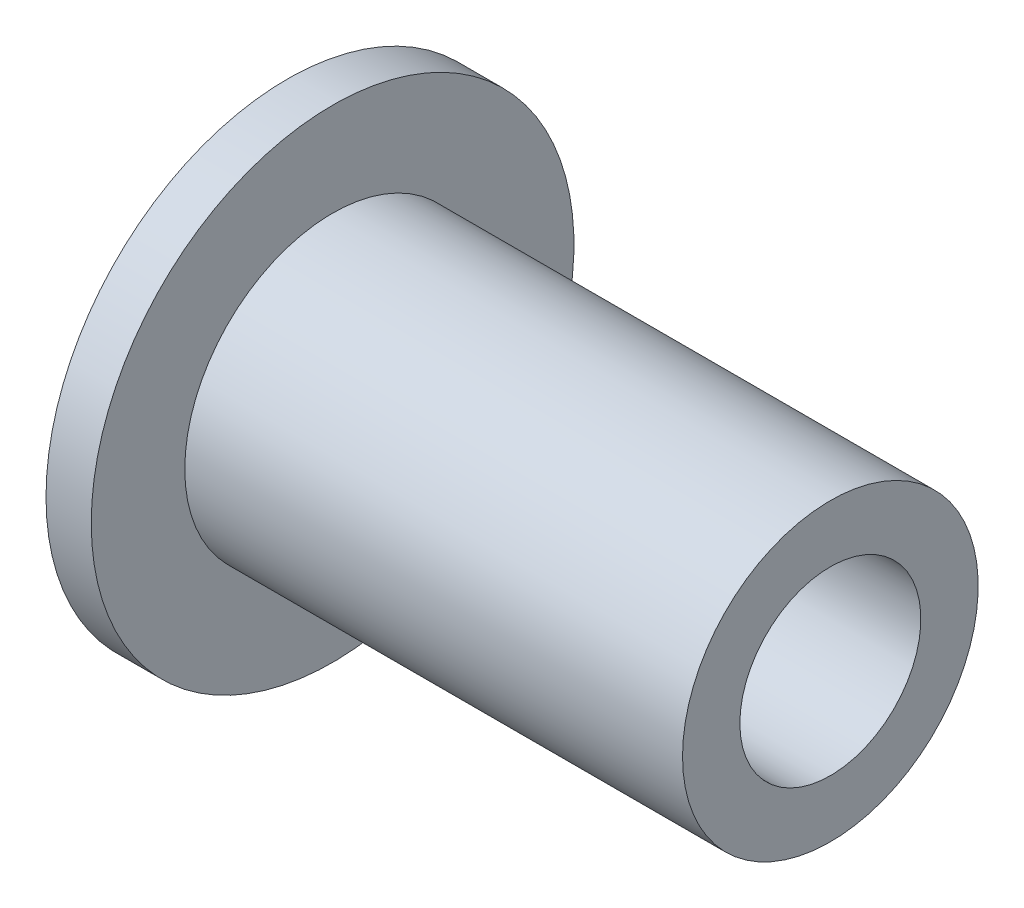
from build123d import *


with BuildPart() as part:
    # 草图1 → 旋转1 (revolve)
    with BuildSketch(Plane.XY):
        Polygon((0, 1.9), (0, 4), (0.75, 4), (0.75, 2.45), (9, 2.45), (9, 1.5), (4, 1.5), (4, 1.9), align=None)
    revolve(axis=Axis((0, 0, 0), (1, 0, 0)))


solid = part.part
